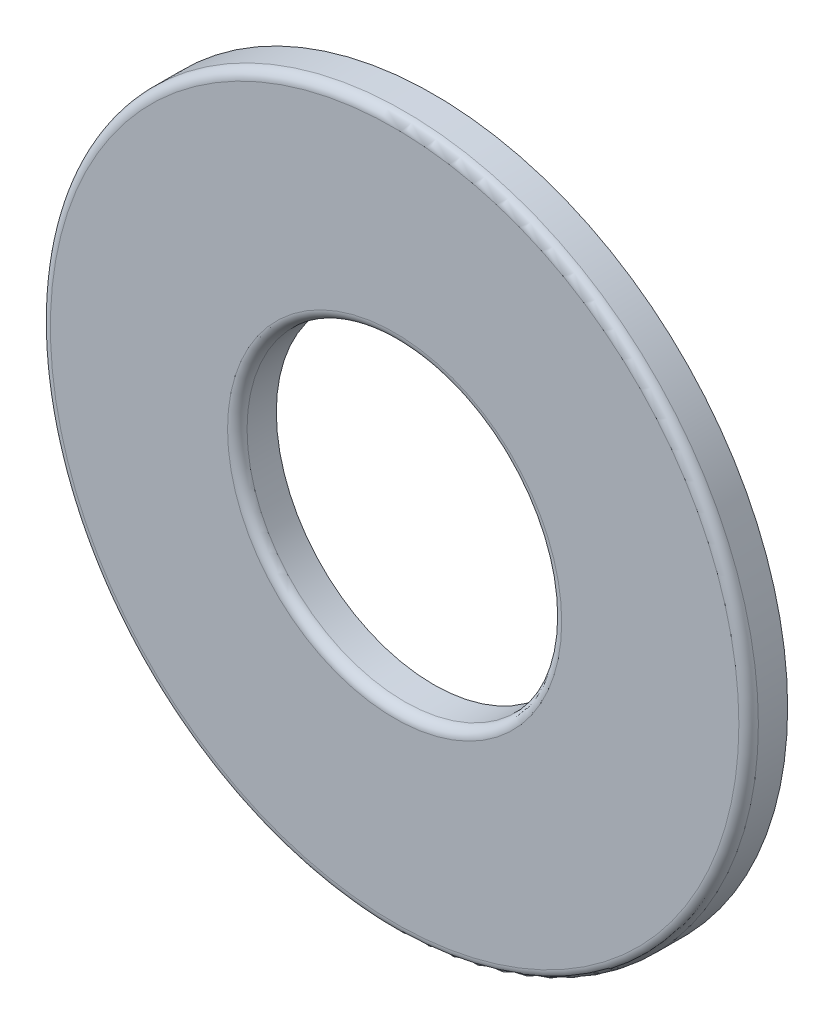
from build123d import *

# Parameters (mm, degrees)
SKETCH3_R                = 14.2875
SKETCH3_R_2              = 6.35
BOSS_EXTRUDE1_DEPTH      = 0.7874
BOSS_EXTRUDE1_DEPTH_BACK = 0.7874
FILLET1_R                = 0.3937


with BuildPart() as part:
    # Sketch3 → Boss-Extrude1 (new body, two sides)
    with BuildSketch(Plane.XY) as boss_extrude1_sk:
        Circle(SKETCH3_R)
        Circle(SKETCH3_R_2, mode=Mode.SUBTRACT)
    extrude(amount=BOSS_EXTRUDE1_DEPTH)
    extrude(boss_extrude1_sk.sketch, amount=-BOSS_EXTRUDE1_DEPTH_BACK)

    # Fillet1
    fillet1_edges = [part.edges().sort_by_distance(p)[0] for p in [
        (-14.2875, 0, 0.7874),
        (-6.35, 0, 0.7874),
    ]]
    fillet(fillet1_edges, radius=FILLET1_R)


solid = part.part
